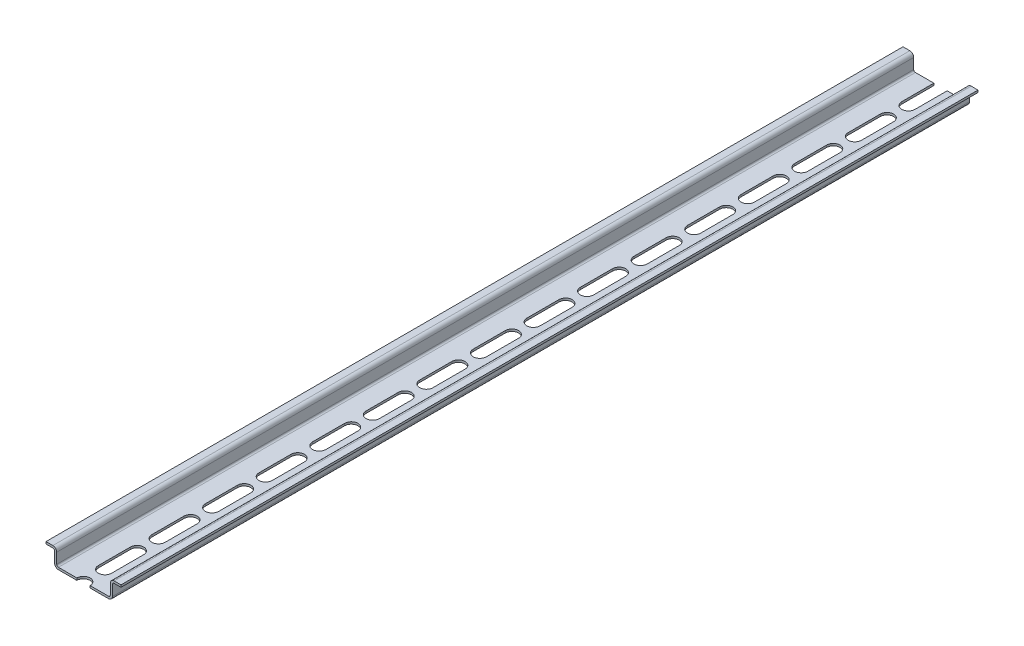
from build123d import *

# Parameters (mm, degrees)
BOSS_EXTRUDE2_DEPTH = 400
CUT_EXTRUDE1_DEPTH  = 100


with BuildPart() as part:
    # Sketch1 → Boss-Extrude2 (new body)
    with BuildSketch(Plane.XY):
        with BuildLine():
            Line((0, 0), (-11.7, 0))
            ThreePointArc((-11.7, 0), (-12.972792206, 0.527207794), (-13.5, 1.8))
            Line((-13.5, 1.8), (-13.5, 6.7))
            ThreePointArc((-13.5, 6.7), (-13.734314575, 7.265685425), (-14.3, 7.5))
            Line((-14.3, 7.5), (-17.5, 7.5))
            Line((-17.5, 7.5), (-17.5, 8.5))
            Line((-17.5, 8.5), (-14.3, 8.5))
            ThreePointArc((-14.3, 8.5), (-13.027207794, 7.972792206), (-12.5, 6.7))
            Line((-12.5, 6.7), (-12.5, 1.8))
            ThreePointArc((-12.5, 1.8), (-12.265685425, 1.234314575), (-11.7, 1))
            Line((-11.7, 1), (0, 1))
            Line((0, 1), (11.7, 1))
            ThreePointArc((11.7, 1), (12.265685425, 1.234314575), (12.5, 1.8))
            Line((12.5, 1.8), (12.5, 6.7))
            ThreePointArc((12.5, 6.7), (13.027207794, 7.972792206), (14.3, 8.5))
            Line((14.3, 8.5), (17.5, 8.5))
            Line((17.5, 8.5), (17.5, 7.5))
            Line((17.5, 7.5), (14.3, 7.5))
            ThreePointArc((14.3, 7.5), (13.734314575, 7.265685425), (13.5, 6.7))
            Line((13.5, 6.7), (13.5, 1.8))
            ThreePointArc((13.5, 1.8), (12.972792206, 0.527207794), (11.7, 0))
            Line((11.7, 0), (0, 0))
        make_face()
    extrude(amount=BOSS_EXTRUDE2_DEPTH)

    # Sketch2 → Cut-Extrude1 (cut)
    with BuildSketch(Plane(origin=(0, 1, 0), x_dir=(1, 0, 0), z_dir=(0, 1, 0))):
        with BuildLine():
            Line((-3.1, -390), (-3.1, -375))
            ThreePointArc((-3.1, -375), (0, -371.9), (3.1, -375))
            Line((3.1, -375), (3.1, -390))
            ThreePointArc((3.1, -390), (0, -393.1), (-3.1, -390))
        make_face()
        with BuildLine():
            Line((-3.1, -365), (-3.1, -350))
            ThreePointArc((-3.1, -350), (0, -346.9), (3.1, -350))
            Line((3.1, -350), (3.1, -365))
            ThreePointArc((3.1, -365), (0, -368.1), (-3.1, -365))
        make_face()
        with BuildLine():
            Line((-3.1, -340), (-3.1, -325))
            ThreePointArc((-3.1, -325), (0, -321.9), (3.1, -325))
            Line((3.1, -325), (3.1, -340))
            ThreePointArc((3.1, -340), (0, -343.1), (-3.1, -340))
        make_face()
        with BuildLine():
            Line((-3.1, -315), (-3.1, -300))
            ThreePointArc((-3.1, -300), (0, -296.9), (3.1, -300))
            Line((3.1, -300), (3.1, -315))
            ThreePointArc((3.1, -315), (0, -318.1), (-3.1, -315))
        make_face()
        with BuildLine():
            Line((-3.1, -415), (-3.1, -400))
            ThreePointArc((-3.1, -400), (0, -396.9), (3.1, -400))
            Line((3.1, -400), (3.1, -415))
            ThreePointArc((3.1, -415), (0, -418.1), (-3.1, -415))
        make_face()
        with BuildLine():
            Line((-3.1, -290), (-3.1, -275))
            ThreePointArc((-3.1, -275), (0, -271.9), (3.1, -275))
            Line((3.1, -275), (3.1, -290))
            ThreePointArc((3.1, -290), (0, -293.1), (-3.1, -290))
        make_face()
        with BuildLine():
            Line((-3.1, -265), (-3.1, -250))
            ThreePointArc((-3.1, -250), (0, -246.9), (3.1, -250))
            Line((3.1, -250), (3.1, -265))
            ThreePointArc((3.1, -265), (0, -268.1), (-3.1, -265))
        make_face()
        with BuildLine():
            Line((-3.1, -240), (-3.1, -225))
            ThreePointArc((-3.1, -225), (0, -221.9), (3.1, -225))
            Line((3.1, -225), (3.1, -240))
            ThreePointArc((3.1, -240), (0, -243.1), (-3.1, -240))
        make_face()
        with BuildLine():
            Line((-3.1, -215), (-3.1, -200))
            ThreePointArc((-3.1, -200), (0, -196.9), (3.1, -200))
            Line((3.1, -200), (3.1, -215))
            ThreePointArc((3.1, -215), (0, -218.1), (-3.1, -215))
        make_face()
        with BuildLine():
            Line((-3.1, -190), (-3.1, -175))
            ThreePointArc((-3.1, -175), (0, -171.9), (3.1, -175))
            Line((3.1, -175), (3.1, -190))
            ThreePointArc((3.1, -190), (0, -193.1), (-3.1, -190))
        make_face()
        with BuildLine():
            Line((-3.1, -165), (-3.1, -150))
            ThreePointArc((-3.1, -150), (0, -146.9), (3.1, -150))
            Line((3.1, -150), (3.1, -165))
            ThreePointArc((3.1, -165), (0, -168.1), (-3.1, -165))
        make_face()
        with BuildLine():
            Line((-3.1, -140), (-3.1, -125))
            ThreePointArc((-3.1, -125), (0, -121.9), (3.1, -125))
            Line((3.1, -125), (3.1, -140))
            ThreePointArc((3.1, -140), (0, -143.1), (-3.1, -140))
        make_face()
        with BuildLine():
            Line((-3.1, -115), (-3.1, -100))
            ThreePointArc((-3.1, -100), (0, -96.9), (3.1, -100))
            Line((3.1, -100), (3.1, -115))
            ThreePointArc((3.1, -115), (0, -118.1), (-3.1, -115))
        make_face()
        with BuildLine():
            Line((-3.1, -90), (-3.1, -75))
            ThreePointArc((-3.1, -75), (0, -71.9), (3.1, -75))
            Line((3.1, -75), (3.1, -90))
            ThreePointArc((3.1, -90), (0, -93.1), (-3.1, -90))
        make_face()
        with BuildLine():
            Line((-3.1, -65), (-3.1, -50))
            ThreePointArc((-3.1, -50), (0, -46.9), (3.1, -50))
            Line((3.1, -50), (3.1, -65))
            ThreePointArc((3.1, -65), (0, -68.1), (-3.1, -65))
        make_face()
        with BuildLine():
            Line((-3.1, -40), (-3.1, -25))
            ThreePointArc((-3.1, -25), (0, -21.9), (3.1, -25))
            Line((3.1, -25), (3.1, -40))
            ThreePointArc((3.1, -40), (0, -43.1), (-3.1, -40))
        make_face()
        with BuildLine():
            Line((-3.1, -15), (-3.1, 0))
            ThreePointArc((-3.1, 0), (0, 3.1), (3.1, 0))
            Line((3.1, 0), (3.1, -15))
            ThreePointArc((3.1, -15), (0, -18.1), (-3.1, -15))
        make_face()
    extrude(amount=-CUT_EXTRUDE1_DEPTH, mode=Mode.SUBTRACT)


solid = part.part
